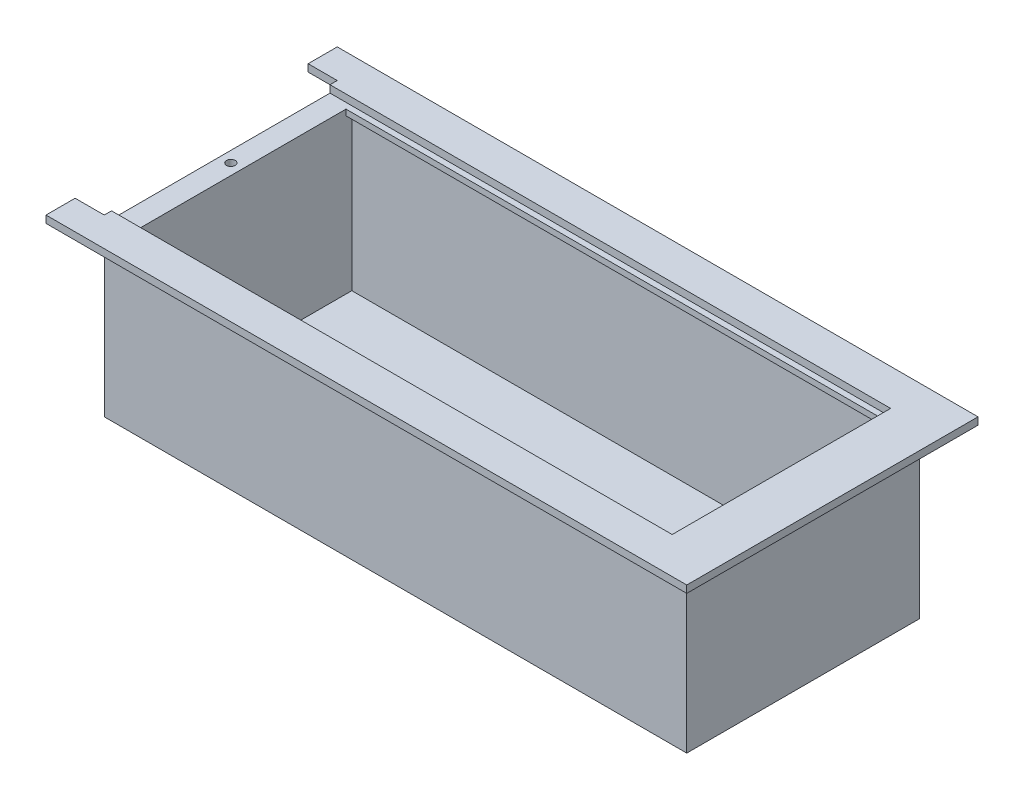
from build123d import *

# Parameters (mm, degrees)
SKETCH1_W            = 200
SKETCH1_H            = 60
BOSS_EXTRUDE1_DEPTH  = 80
SKETCH2_W            = 185
SKETCH2_H            = 75
CUT_EXTRUDE1_DEPTH   = 57.5
SKETCH3_W            = 7.5
SKETCH3_H            = 75
CUT_EXTRUDE2_DEPTH   = 2.5
SKETCH4_W            = 210
SKETCH4_H            = 2.5
BOSS_EXTRUDE7_DEPTH  = 10
SKETCH9_W            = 210
SKETCH9_H            = 2.5
BOSS_EXTRUDE8_DEPTH  = 10
SKETCH10_W           = 100
SKETCH10_H           = 2.5
BOSS_EXTRUDE9_DEPTH  = 10
SKETCH11_R           = 1.5
CUT_EXTRUDE3_DEPTH   = 5
SKETCH12_W           = 185
SKETCH12_H           = 2
BOSS_EXTRUDE11_DEPTH = 2
SKETCH13_W           = 185
SKETCH13_H           = 2
BOSS_EXTRUDE12_DEPTH = 2
SKETCH14_W           = 55
SKETCH14_H           = 2.5
CUT_EXTRUDE4_DEPTH   = 3
SKETCH15_W           = 25
SKETCH15_H           = 15
CUT_EXTRUDE5_DEPTH   = 2.5


with BuildPart() as part:
    # Sketch1 → Boss-Extrude1 (new body)
    with BuildSketch(Plane.XY):
        with Locations((100, 30)):
            Rectangle(SKETCH1_W, SKETCH1_H)
    extrude(amount=BOSS_EXTRUDE1_DEPTH)

    # Sketch2 → Cut-Extrude1 (cut)
    with BuildSketch(Plane(origin=(0, 60, 0), x_dir=(1, 0, 0), z_dir=(0, 1, 0))):
        with Locations((100, -40)):
            Rectangle(SKETCH2_W, SKETCH2_H)
    extrude(amount=-CUT_EXTRUDE1_DEPTH, mode=Mode.SUBTRACT)

    # Sketch3 → Cut-Extrude2 (cut)
    with BuildSketch(Plane(origin=(0, 60, 0), x_dir=(1, 0, 0), z_dir=(0, 1, 0))):
        with Locations((3.75, -40)):
            Rectangle(SKETCH3_W, SKETCH3_H)
    extrude(amount=-CUT_EXTRUDE2_DEPTH, mode=Mode.SUBTRACT)

    # Sketch4 → Boss-Extrude7 (add)
    with BuildSketch(Plane(origin=(0, 0, 0), x_dir=(-1, 0, 0), z_dir=(0, 0, -1))):
        with Locations((-95, 58.75)):
            Rectangle(SKETCH4_W, SKETCH4_H)
    extrude(amount=BOSS_EXTRUDE7_DEPTH)

    # Sketch9 → Boss-Extrude8 (add)
    with BuildSketch(Plane.XY.offset(80)):
        with Locations((95, 58.75)):
            Rectangle(SKETCH9_W, SKETCH9_H)
    extrude(amount=BOSS_EXTRUDE8_DEPTH)

    # Sketch10 → Boss-Extrude9 (add)
    with BuildSketch(Plane(origin=(200, 0, 0), x_dir=(0, 0, -1), z_dir=(1, 0, 0))):
        with Locations((-40, 58.75)):
            Rectangle(SKETCH10_W, SKETCH10_H)
    extrude(amount=BOSS_EXTRUDE9_DEPTH)

    # Sketch11 → Cut-Extrude3 (cut)
    with BuildSketch(Plane(origin=(0, 57.5, 0), x_dir=(1, 0, 0), z_dir=(0, 1, 0))):
        with Locations((3.75, -40.265298021)):
            Circle(SKETCH11_R)
    extrude(amount=-CUT_EXTRUDE3_DEPTH, mode=Mode.SUBTRACT)

    # Sketch12 → Boss-Extrude11 (add)
    with BuildSketch(Plane(origin=(0, 0, 77.5), x_dir=(-1, 0, 0), z_dir=(0, 0, -1))):
        with Locations((-100, 56.5)):
            Rectangle(SKETCH12_W, SKETCH12_H)
    extrude(amount=BOSS_EXTRUDE11_DEPTH)

    # Sketch13 → Boss-Extrude12 (add)
    with BuildSketch(Plane.XY.offset(2.5)):
        with Locations((100, 56.5)):
            Rectangle(SKETCH13_W, SKETCH13_H)
    extrude(amount=BOSS_EXTRUDE12_DEPTH)

    # Sketch14 → Cut-Extrude4 (cut)
    with BuildSketch(Plane.ZY.offset(-192.5)):
        with Locations((40, 56.25)):
            Rectangle(SKETCH14_W, SKETCH14_H)
    extrude(amount=-CUT_EXTRUDE4_DEPTH, mode=Mode.SUBTRACT)

    # Sketch15 → Cut-Extrude5 (cut)
    with BuildSketch(Plane(origin=(0, 2.5, 0), x_dir=(1, 0, 0), z_dir=(0, 1, 0))):
        with Locations((30, -40)):
            Rectangle(SKETCH15_W, SKETCH15_H)
    extrude(amount=-CUT_EXTRUDE5_DEPTH, mode=Mode.SUBTRACT)


solid = part.part
